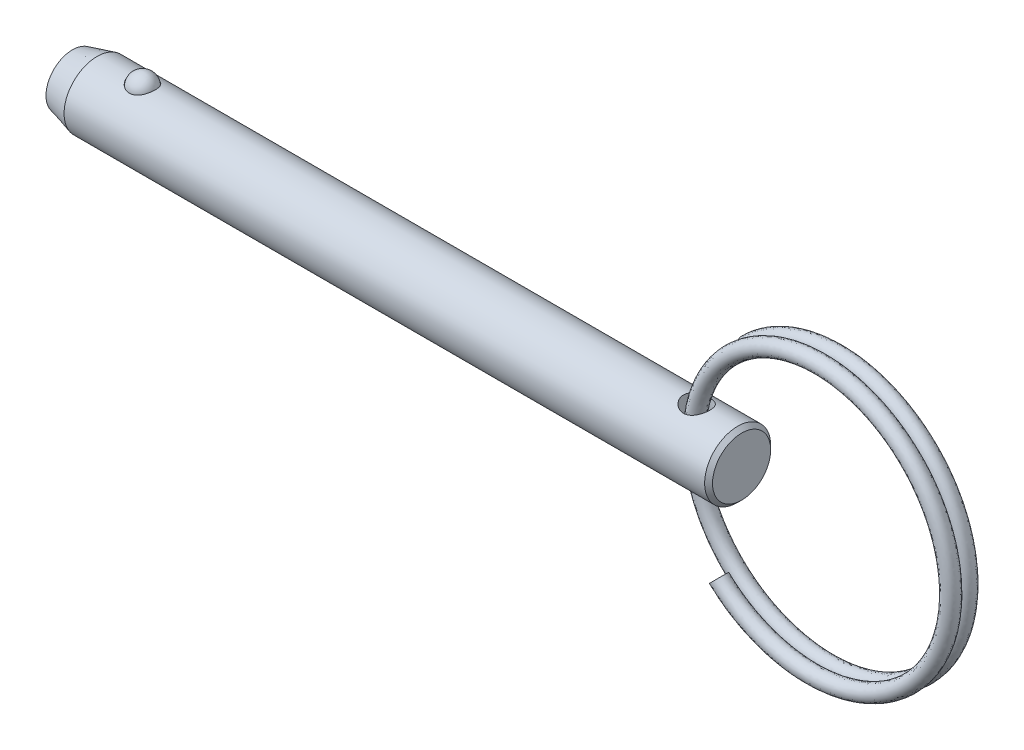
from build123d import *

# Parameters (mm, degrees)
SKETCH4_W          = 1.27
SKETCH4_H          = 6.35
SWEEP1_PITCH       = 1.5494
SWEEP1_HEIGHT      = 1.355725
SWEEP1_RADIUS      = 13.462
SKETCH6_R          = 0.762
SWEEP2_PITCH       = 1.5494
SWEEP2_HEIGHT      = 1.355725
SWEEP2_RADIUS      = 13.462
SWEEP2_START_ANGLE = -180
SKETCH6_2_R        = 0.762


with BuildPart() as part:
    # Sketch1 → Revolve1 (revolve)
    with BuildSketch(Plane.XY):
        Polygon((32.1564, 2.794), (31.7754, 3.175), (-29.786547737, 3.175), (-32.1564, 2.54), (-32.1564, 0), (32.1564, 0), align=None)
    revolve(axis=Axis((32.1564, 0, 0), (1, 0, 0)))

    # Sketch2 → Cut-Revolve1 (revolve, cut)
    with BuildSketch(Plane.XY):
        with BuildLine():
            Line((-24.164582051, 2.8575), (-26.679182051, 2.8575))
            ThreePointArc((-26.679182051, 2.8575), (-25.421882051, 4.1148), (-24.164582051, 2.8575))
        make_face()
    revolve(axis=Axis((-24.164582051, 2.8575, 0), (1, 0, 0)), mode=Mode.SUBTRACT)

    # Sketch4 → Cut-Revolve2 (revolve, cut)
    with BuildSketch(Plane.XY):
        with Locations((28.4734, 0)):
            Rectangle(SKETCH4_W, SKETCH4_H)
    revolve(axis=Axis((27.8384, -3.175, 0), (0, 1, 0)), mode=Mode.SUBTRACT)


with BuildPart() as body_2:
    # Sketch3 → Revolve2 (revolve)
    with BuildSketch(Plane.XY):
        with BuildLine():
            Line((-24.189982051, 2.8575), (-26.653782051, 2.8575))
            ThreePointArc((-26.653782051, 2.8575), (-25.421882051, 4.0894), (-24.189982051, 2.8575))
        make_face()
    revolve(axis=Axis((-24.189982051, 2.8575, 0), (1, 0, 0)))


with BuildPart() as body_3:
    # Sweep1: sweep along a helix
    with BuildLine() as sweep1_path:
        Helix(SWEEP1_PITCH, SWEEP1_HEIGHT, SWEEP1_RADIUS, center=(40.323425091, 0, 0), direction=(0, 0, -1), lefthand=True)
    # Sketch6 → Sweep1 (sweep)
    with BuildSketch(Plane(origin=(114.003847968, 0, 0), x_dir=(0, 0, -1), z_dir=(0, 1, 0))):
        with Locations((0, 86.380422877)):
            Circle(SKETCH6_R)
    sweep(path=sweep1_path.line, is_frenet=True)

    # Sweep2: sweep along a helix
    with BuildLine() as sweep2_path:
        add(Helix(SWEEP2_PITCH, SWEEP2_HEIGHT, SWEEP2_RADIUS, center=(40.323425091, 0, 0), direction=(0, 0, 1), lefthand=True, mode=Mode.PRIVATE).rotate(Axis((40.323425091, 0, 0), (0, 0, 1)), SWEEP2_START_ANGLE))
    # Sketch6_2 → Sweep2 (sweep)
    with BuildSketch(Plane(origin=(114.003847968, 0, 0), x_dir=(0, 0, -1), z_dir=(0, 1, 0))):
        with Locations((0, 86.380422877)):
            Circle(SKETCH6_2_R)
    sweep(path=sweep2_path.line, is_frenet=True)


solid = Compound([part.part, body_2.part, body_3.part])
